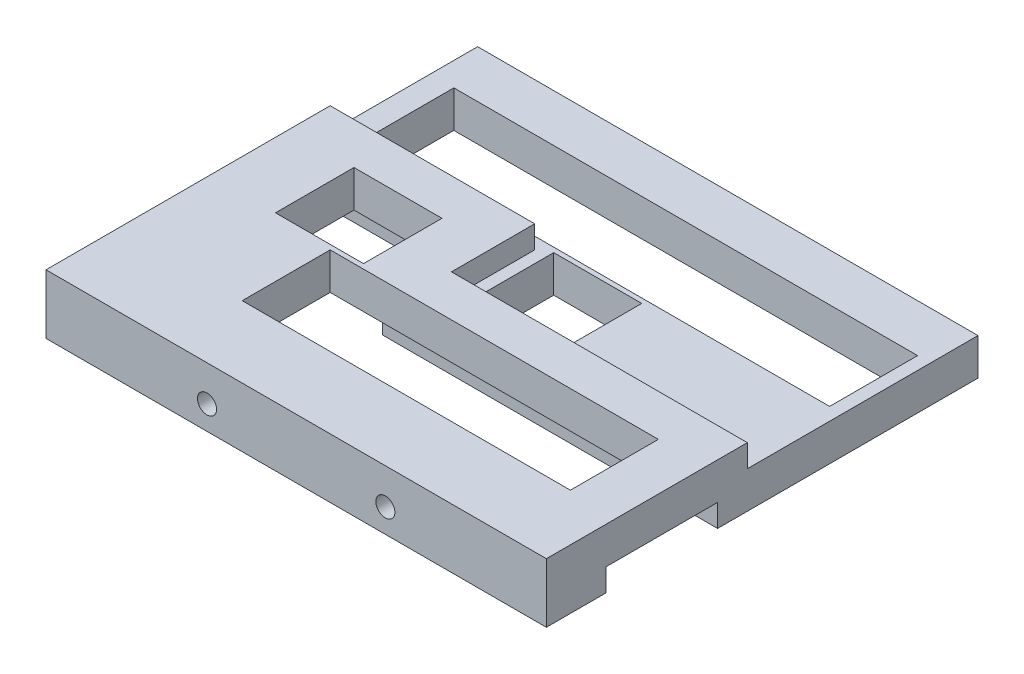
from build123d import *

# Parameters (mm, degrees)
SKETCH1_W                 = 210.4
SKETCH1_H                 = 181.5
SKETCH1_W_2               = 138
SKETCH1_H_2               = 37
SKETCH1_W_3               = 37
SKETCH1_H_3               = 33
SKETCH1_W_4               = 195
BOSS_EXTRUDE1_DEPTH       = 25
SKETCH2_W                 = 37
SKETCH2_H                 = 33
SKETCH2_W_2               = 195
SKETCH2_H_2               = 37
CUT_EXTRUDE1_DEPTH        = 282.126821915
CUT_EXTRUDE1_DEPTH_BACK   = 9.5
SKETCH3_W                 = 37
SKETCH3_H                 = 33
SKETCH3_W_2               = 138
SKETCH3_H_2               = 37
CUT_EXTRUDE2_DEPTH        = 282.126821915
CUT_EXTRUDE2_DEPTH_BACK   = 9.5
F_8_0MM_DOWEL_HOLE1_D     = 8
F_8_0MM_DOWEL_HOLE1_DEPTH = 25


with BuildPart() as part:
    # Sketch1 → Boss-Extrude1 (new body)
    with BuildSketch(Plane(origin=(0, 0, 0), x_dir=(1, 0, 0), z_dir=(0, 1, 0))):
        with Locations((0, 168.75)):
            Rectangle(SKETCH1_W, SKETCH1_H)
        with Locations((16.3, 126.5)):
            Rectangle(SKETCH1_W_2, SKETCH1_H_2, mode=Mode.SUBTRACT)
        with Locations((-59.2, 163.5)):
            Rectangle(SKETCH1_W_3, SKETCH1_H_3, mode=Mode.SUBTRACT)
        with Locations((4.3, 184)):
            Rectangle(SKETCH1_W_3, SKETCH1_H_3, mode=Mode.SUBTRACT)
        with Locations((2.3, 221)):
            Rectangle(SKETCH1_W_4, SKETCH1_H_2, mode=Mode.SUBTRACT)
    extrude(amount=BOSS_EXTRUDE1_DEPTH)

    # Sketch2 → Cut-Extrude1 (cut, two sides)
    with BuildSketch(Plane(origin=(0, 25, 0), x_dir=(1, 0, 0), z_dir=(0, 1, 0))) as cut_extrude1_sk:
        Polygon((-105.2, 259.5), (-105.2, 197.5), (-19.2, 197.5), (-19.2, 162.5), (105.2, 162.5), (105.2, 259.5), align=None)
        with Locations((4.3, 184)):
            Rectangle(SKETCH2_W, SKETCH2_H, mode=Mode.SUBTRACT)
        with Locations((2.3, 221)):
            Rectangle(SKETCH2_W_2, SKETCH2_H_2, mode=Mode.SUBTRACT)
    extrude(amount=CUT_EXTRUDE1_DEPTH, mode=Mode.SUBTRACT)
    extrude(cut_extrude1_sk.sketch, amount=-CUT_EXTRUDE1_DEPTH_BACK, mode=Mode.SUBTRACT)

    # Sketch3 → Cut-Extrude2 (cut, two sides)
    with BuildSketch(Plane.XZ) as cut_extrude2_sk:
        Polygon((-105.2, -103), (-105.2, -185), (-35.7, -185), (-35.7, -150), (105.2, -150), (105.2, -103), align=None)
        with Locations((-59.2, -163.5)):
            Rectangle(SKETCH3_W, SKETCH3_H, mode=Mode.SUBTRACT)
        with Locations((16.3, -126.5)):
            Rectangle(SKETCH3_W_2, SKETCH3_H_2, mode=Mode.SUBTRACT)
    extrude(amount=CUT_EXTRUDE2_DEPTH, mode=Mode.SUBTRACT)
    extrude(cut_extrude2_sk.sketch, amount=-CUT_EXTRUDE2_DEPTH_BACK, mode=Mode.SUBTRACT)

    # Ø8.0mm Dowel Hole1
    with Locations(Plane(origin=(-37.5, 10, -78), x_dir=(1, 0, 0), z_dir=(0, 0, 1))):
        with Locations((0, 0), (75, 0)):
            Hole(F_8_0MM_DOWEL_HOLE1_D / 2, depth=F_8_0MM_DOWEL_HOLE1_DEPTH)


solid = part.part
